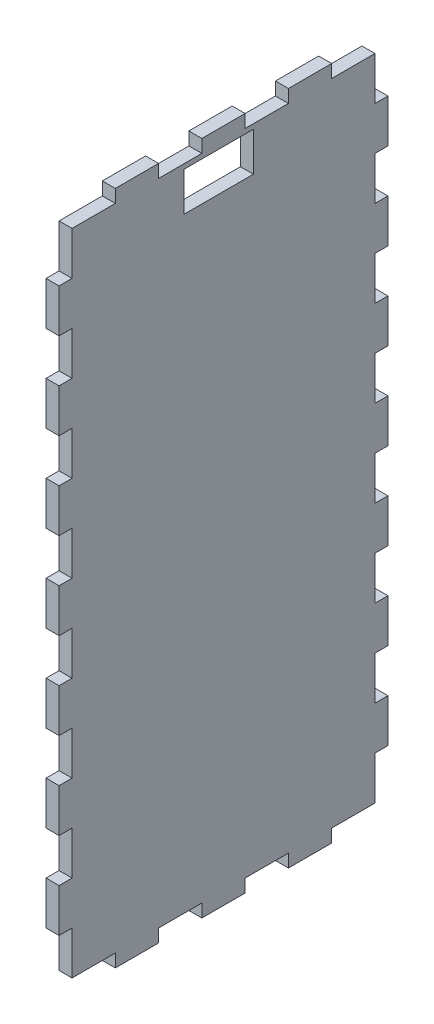
from build123d import *

# Parameters (mm, degrees)
SKETCH1_W           = 16
SKETCH1_H           = 9
BOSS_EXTRUDE1_DEPTH = 3


with BuildPart() as part:
    # Sketch1 → Boss-Extrude1 (new body)
    with BuildSketch(Plane(origin=(0, 0, 0), x_dir=(0, 0, -1), z_dir=(1, 0, 0))):
        Polygon((10, 153.005875518), (20, 153.005875518), (20, 150.005875518), (30, 150.005875518), (30, 153.005875518), (40, 153.005875518), (40, 150.005875518), (50, 150.005875518), (50, 153.005875518), (60, 153.005875518), (60, 150.005875518), (70, 150.005875518), (70, 140), (73, 140), (73, 130), (70, 130), (70, 120), (73, 120), (73, 110), (70, 110), (70, 100), (73, 100), (73, 90), (70, 90), (70, 80), (73, 80), (73, 70), (70, 70), (70, 60), (73, 60), (73, 50), (70, 50), (70, 40), (73, 40), (73, 30), (70, 30), (70, 20), (73, 20), (73, 10), (70, 10), (70, 0), (60, 0), (60, -3), (50, -3), (50, 0), (40, 0), (40, -3), (30, -3), (30, 0), (20, 0), (20, -3), (10, -3), (10, 0), (0, 0), (0, 10), (-3, 10), (-3, 20), (0, 20), (0, 30), (-3, 30), (-3, 40), (0, 40), (0, 50), (-3, 50), (-3, 60), (0, 60), (0, 70), (-3, 70), (-3, 80), (0, 80), (0, 90), (-3, 90), (-3, 100), (0, 100), (0, 110), (-3, 110), (-3, 120), (0, 120), (0, 130), (-3, 130), (-3, 140), (0, 140), (0, 150.005875518), (10, 150.005875518), align=None)
        with Locations((33.90899457, 144.39356925)):
            Rectangle(SKETCH1_W, SKETCH1_H, mode=Mode.SUBTRACT)
    extrude(amount=BOSS_EXTRUDE1_DEPTH)


solid = part.part
